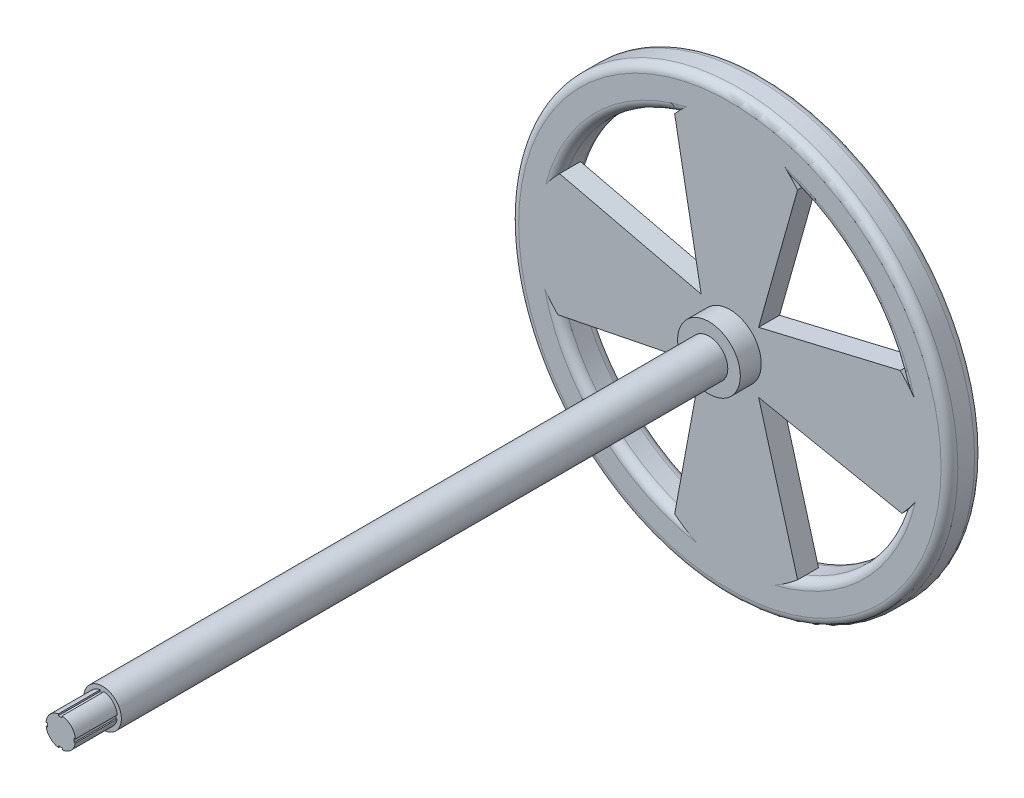
from build123d import *

# Parameters (mm, degrees)
SKETCH1_R           = 133.35
SKETCH1_R_2         = 110.49
BOSS_EXTRUDE1_DEPTH = 20.32
FILLET1_R           = 5.08
FILLET4_R           = 5.08
FILLET5_R           = 5.08
FILLET6_R           = 5.08
SKETCH2_R           = 25.4
BOSS_EXTRUDE2_DEPTH = 12.7
SKETCH3_R           = 11.43
BOSS_EXTRUDE3_DEPTH = 381
BOSS_EXTRUDE4_DEPTH = 25.4
SKETCH5_R           = 19.05
BOSS_EXTRUDE5_DEPTH = 12.7


with BuildPart() as part:
    # Sketch1 → Boss-Extrude1 (new body)
    with BuildSketch(Plane.XY):
        Circle(SKETCH1_R)
        Circle(SKETCH1_R_2, mode=Mode.SUBTRACT)
    extrude(amount=BOSS_EXTRUDE1_DEPTH)

    # Fillet1
    fillet1_edges = [part.edges().sort_by_distance(p)[0] for p in [
        (-133.35, 0, 20.32),
    ]]
    fillet(fillet1_edges, radius=FILLET1_R)

    # Fillet4
    fillet4_edges = [part.edges().sort_by_distance(p)[0] for p in [
        (-133.35, 0, 0),
    ]]
    fillet(fillet4_edges, radius=FILLET4_R)

    # Fillet5
    fillet5_edges = [part.edges().sort_by_distance(p)[0] for p in [
        (-110.49, 0, 20.32),
    ]]
    fillet(fillet5_edges, radius=FILLET5_R)

    # Fillet6
    fillet6_edges = [part.edges().sort_by_distance(p)[0] for p in [
        (-110.49, 0, 0),
    ]]
    fillet(fillet6_edges, radius=FILLET6_R)



with BuildPart() as body_2:
    # Sketch2 → Boss-Extrude2 (new body)
    with BuildSketch(Plane.XY.offset(20.32)):
        with BuildLine():
            add(Edge.make_bspline(
                [(111.995773379, 28.519671196), (108.395461325, 33.640925655), (103.465758881, 38.766955506)],
                knots=[0.86323948, 0.86323948, 0.86323948, 1, 1, 1], degree=2))
            Line((103.465758881, 38.766955506), (17.465361403, 18.442373791))
            ThreePointArc((17.465361403, 18.442373791), (23.332168562, 10.038421698), (25.4, 0))
            ThreePointArc((25.4, 0), (23.332168562, -10.038421698), (17.465361403, -18.442373791))
            Line((17.465361403, -18.442373791), (104.480917214, -35.941313806))
            add(Edge.make_bspline(
                [(104.480917214, -35.941313806), (109.199570697, -30.926942984), (112.628608991, -25.907939648)],
                knots=[0, 0, 0, 0.134699054, 0.134699054, 0.134699054], degree=2))
            ThreePointArc((112.628608991, -25.907939648), (114.832297811, -13.037188327), (115.57, 0))
            ThreePointArc((115.57, 0), (114.672962004, 14.37138425), (111.995773379, 28.519671196))
        make_face()
        with BuildLine():
            ThreePointArc((-17.465361403, 18.442373791), (0, 25.4), (17.465361403, 18.442373791))
            Line((17.465361403, 18.442373791), (41.120888712, 102.55297466))
            add(Edge.make_bspline(
                [(33.408134269, 110.6359863), (37.257292789, 107.035833442), (41.120888712, 102.55297466)],
                knots=[0.898413925, 0.898413925, 0.898413925, 1, 1, 1], degree=2))
            ThreePointArc((33.408134269, 110.6359863), (3.618968694, 115.513323758), (-26.417084957, 112.510277408))
            add(Edge.make_bspline(
                [(-33.5455644, 105.274570572), (-29.987921782, 109.295772293), (-26.417084957, 112.510277408)],
                knots=[0, 0, 0, 0.097113874, 0.097113874, 0.097113874], degree=2))
            Line((-33.5455644, 105.274570572), (-17.465361403, 18.442373791))
        make_face()
        with BuildLine():
            Line((41.120888883, -102.552974591), (17.465361403, -18.442373791))
            ThreePointArc((17.465361403, -18.442373791), (0, -25.4), (-17.465361403, -18.442373791))
            Line((-17.465361403, -18.442373791), (-33.545564575, -105.274570516))
            add(Edge.make_bspline(
                [(-33.545564575, -105.274570516), (-26.738144431, -110.571915765), (-19.922448027, -113.839891798)],
                knots=[0, 0, 0, 0.182948004, 0.182948004, 0.182948004], degree=2))
            ThreePointArc((-19.922448027, -113.839891798), (3.568860133, -115.514882753), (26.911965601, -112.392931306))
            add(Edge.make_bspline(
                [(26.911965601, -112.392931306), (34.011973832, -108.564945177), (41.120888883, -102.552974591)],
                knots=[0.810210618, 0.810210618, 0.810210618, 1, 1, 1], degree=2))
        make_face()
        with BuildLine():
            ThreePointArc((-17.465361403, -18.442373791), (-25.4, 0), (-17.465361403, 18.442373791))
            Line((-17.465361403, 18.442373791), (-103.453712161, 38.799092001))
            add(Edge.make_bspline(
                [(-111.872978372, 28.997613871), (-108.286344087, 33.895850119), (-103.453712161, 38.799092001)],
                knots=[0.869248391, 0.869248391, 0.869248391, 1, 1, 1], degree=2))
            ThreePointArc((-111.872978372, 28.997613871), (-115.56181287, 1.375611191), (-112.531537583, -26.326373643))
            add(Edge.make_bspline(
                [(-104.492035357, -35.908977246), (-109.115451856, -31.120100592), (-112.531537583, -26.326373643)],
                knots=[0, 0, 0, 0.128706822, 0.128706822, 0.128706822], degree=2))
            Line((-104.492035357, -35.908977246), (-17.465361403, -18.442373791))
        make_face()
        Circle(SKETCH2_R)
    extrude(amount=-BOSS_EXTRUDE2_DEPTH)


with BuildPart() as part_1:
    add(part.part)

    add(body_2.part)  # Boss-Extrude3 merges body 2
    # Sketch3 → Boss-Extrude3 (add)
    with BuildSketch(Plane.XY.offset(20.32)):
        Circle(SKETCH3_R)
    extrude(amount=BOSS_EXTRUDE3_DEPTH)

    # Sketch4 → Boss-Extrude4 (add)
    with BuildSketch(Plane.XY.offset(401.32)):
        with BuildLine():
            Line((0.984973427, -8.925344441), (0.984973427, -7.883058907))
            Line((0.984973427, -7.883058907), (-1.301026573, -7.883058907))
            Line((-1.301026573, -7.883058907), (-1.301026573, -8.884777763))
            ThreePointArc((-1.301026573, -8.884777763), (-6.277222362, -6.420936494), (-8.853056418, -1.501778309))
            Line((-8.853056418, -1.501778309), (-8.038471669, -1.501778309))
            Line((-8.038471669, -1.501778309), (-8.038471669, 0.784221691))
            Line((-8.038471669, 0.784221691), (-8.945218968, 0.784221691))
            ThreePointArc((-8.945218968, 0.784221691), (-6.582089434, 6.108031166), (-1.449428448, 8.861777655))
            Line((-1.449428448, 8.861777655), (-1.449428448, 7.87722015))
            Line((-1.449428448, 7.87722015), (0.836571552, 7.87722015))
            Line((0.836571552, 7.87722015), (0.836571552, 8.940475048))
            ThreePointArc((0.836571552, 8.940475048), (6.346995913, 6.351975198), (8.939816257, 0.84358244))
            Line((8.939816257, 0.84358244), (8.107652261, 0.84358244))
            Line((8.107652261, 0.84358244), (8.107652261, -1.44241756))
            Line((8.107652261, -1.44241756), (8.862921506, -1.44241756))
            ThreePointArc((8.862921506, -1.44241756), (6.18415777, -6.510617383), (0.984973427, -8.925344441))
        make_face()
    extrude(amount=BOSS_EXTRUDE4_DEPTH)

    # Sketch5 → Boss-Extrude5 (add)
    with BuildSketch(Plane.XY.offset(20.32)):
        Circle(SKETCH5_R)
    extrude(amount=BOSS_EXTRUDE5_DEPTH)


solid = part_1.part
